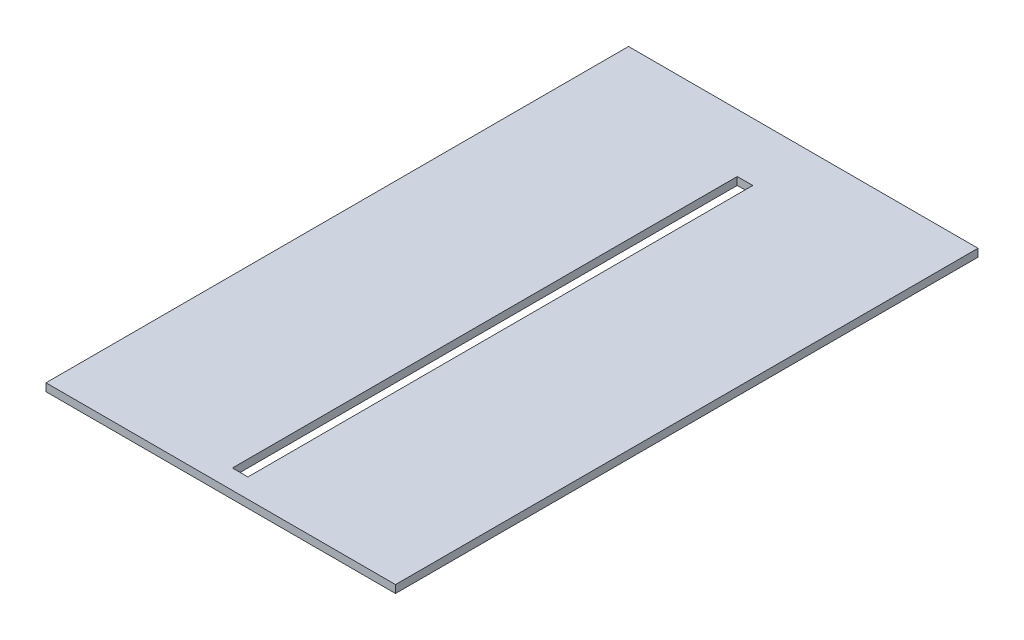
from build123d import *

# Parameters (mm, degrees)
SKETCH_1_W      = 450
SKETCH_1_H      = 750
SKETCH_1_W_2    = 20
SKETCH_1_H_2    = 650
EXTRUDE_1_DEPTH = 10


with BuildPart() as part:
    # Эскиз1 → Бобышка-Вытянуть1 (new body)
    with BuildSketch(Plane(origin=(0, 0, 0), x_dir=(1, 0, 0), z_dir=(0, 1, 0))):
        Rectangle(SKETCH_1_W, SKETCH_1_H)
        with Locations((0, -25)):
            Rectangle(SKETCH_1_W_2, SKETCH_1_H_2, mode=Mode.SUBTRACT)
    extrude(amount=EXTRUDE_1_DEPTH)


solid = part.part
